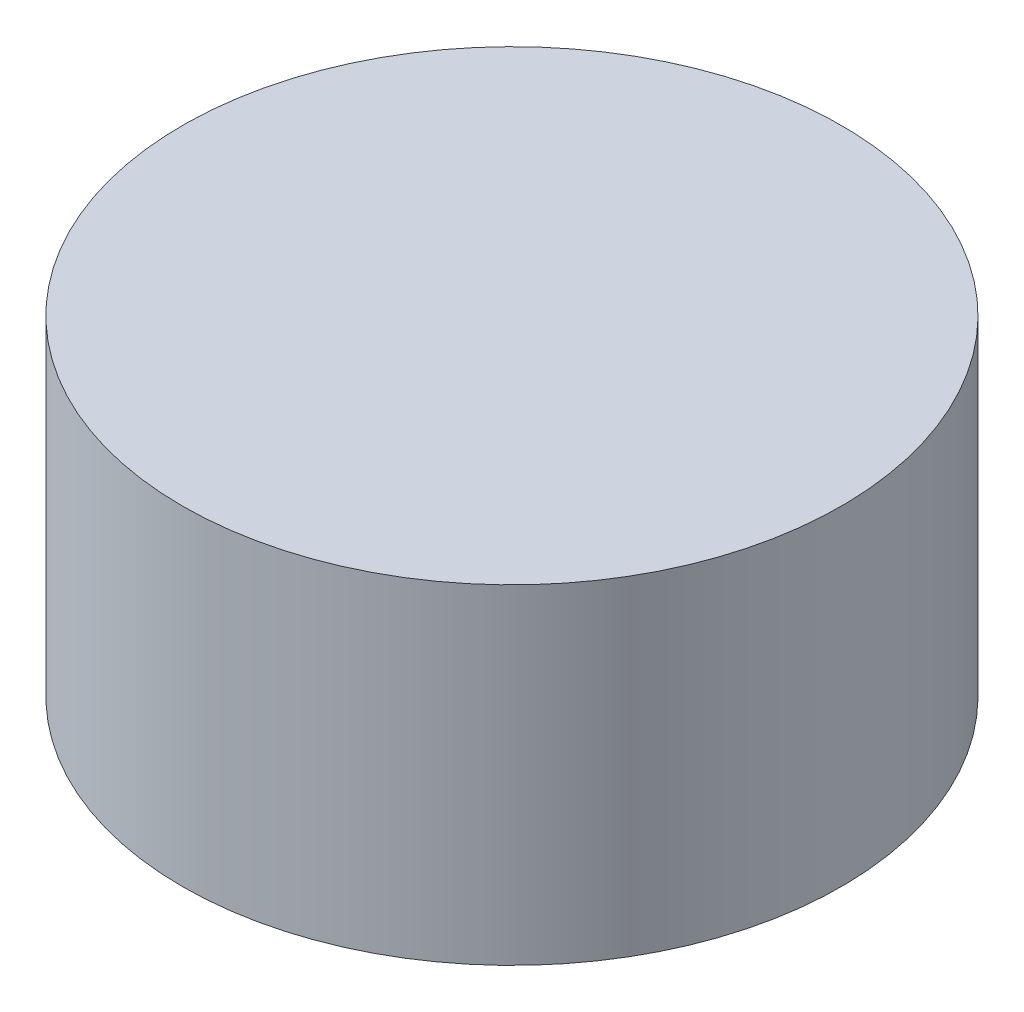
from build123d import *

# Parameters (mm, degrees)
SKETCH_1_W = 7
SKETCH_1_H = 7


with BuildPart() as part:
    # Эскиз1 → Повернуть1 (revolve)
    with BuildSketch(Plane.XY):
        with Locations((-3.5, 3.5)):
            Rectangle(SKETCH_1_W, SKETCH_1_H)
    revolve(axis=Axis((0, 7, 0), (0, -1, 0)))


solid = part.part
